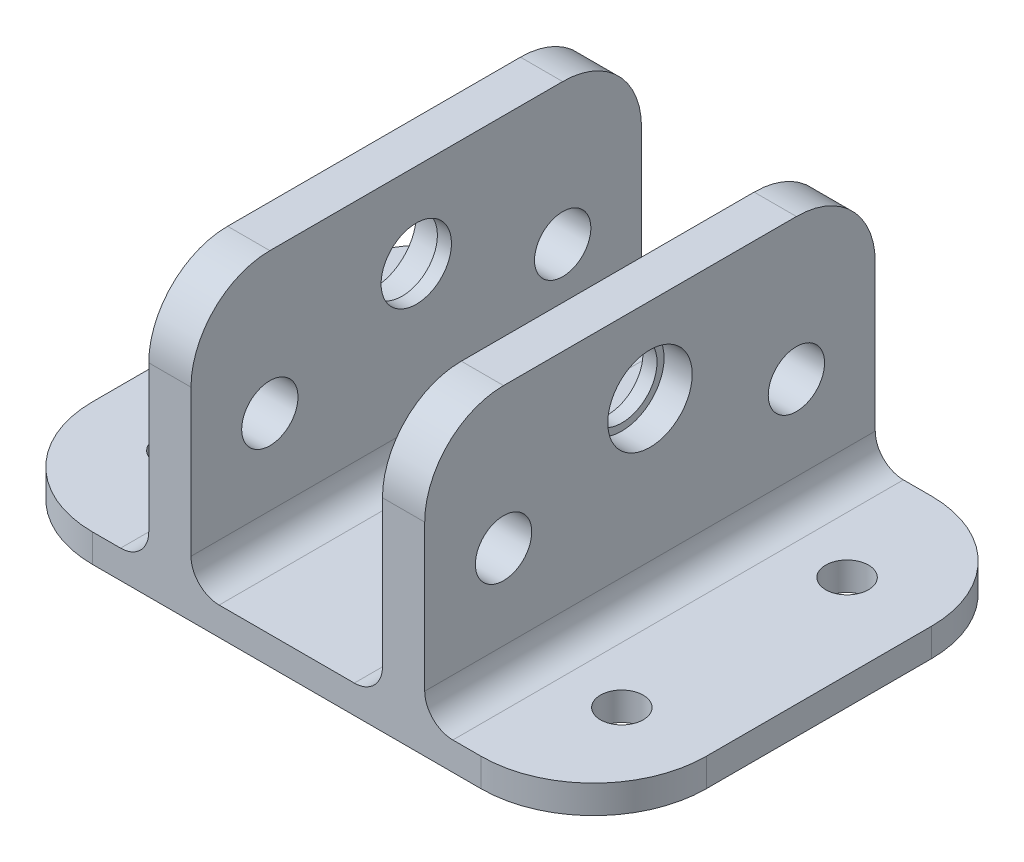
from build123d import *

# Parameters (mm, degrees)
BOSS_EXTRUDE2_DEPTH = 50.8
SKETCH4_R           = 3.175
SKETCH4_R_2         = 3.96875
CUT_EXTRUDE1_DEPTH  = 51.165
SKETCH5_R           = 2.413
CUT_EXTRUDE2_DEPTH  = 4.175
SKETCH4_3_R         = 4.7625
SKETCH4_3_R_2       = 3.96875
CUT_EXTRUDE3_DEPTH  = 3.175
SKETCH6_R           = 4.7625
SKETCH6_R_2         = 3.96875
CUT_EXTRUDE4_DEPTH  = 3.175
FILLET1_R           = 12.7
FILLET2_R           = 3.175
FILLET3_R           = 8.89


with BuildPart() as part:
    # Sketch3 → Boss-Extrude2 (new body)
    with BuildSketch(Plane.XY):
        Polygon((-34.6075, 0), (34.6075, 0), (34.6075, 3.175), (15.5575, 3.175), (15.5575, 31.75), (10.795, 31.75), (10.795, 3.175), (-10.795, 3.175), (-10.795, 31.75), (-15.5575, 31.75), (-15.5575, 3.175), (-34.6075, 3.175), align=None)
    extrude(amount=BOSS_EXTRUDE2_DEPTH)

    # Sketch4 → Cut-Extrude1 (cut, through all)
    with BuildSketch(Plane.ZY.offset(15.5575)):
        with Locations((8.89, 15.875)):
            Circle(SKETCH4_R)
        with Locations((41.91, 15.875)):
            Circle(SKETCH4_R)
        with Locations((25.4, 22.225)):
            Circle(SKETCH4_R_2)
    extrude(amount=-CUT_EXTRUDE1_DEPTH, mode=Mode.SUBTRACT)

    # Sketch5 → Cut-Extrude2 (cut, through all)
    with BuildSketch(Plane(origin=(0, 3.175, 0), x_dir=(1, 0, 0), z_dir=(0, 1, 0))):
        with Locations((-25.0825, -38.1)):
            Circle(SKETCH5_R)
        with Locations((-25.0825, -12.7)):
            Circle(SKETCH5_R)
        with Locations((25.0825, -12.7)):
            Circle(SKETCH5_R)
        with Locations((25.0825, -38.1)):
            Circle(SKETCH5_R)
    extrude(amount=-CUT_EXTRUDE2_DEPTH, mode=Mode.SUBTRACT)

    # Sketch4_3 → Cut-Extrude3 (cut)
    with BuildSketch(Plane.ZY.offset(15.5575)):
        with Locations((25.4, 22.225)):
            Circle(SKETCH4_3_R)
        with Locations((25.4, 22.225)):
            Circle(SKETCH4_3_R_2, mode=Mode.SUBTRACT)
    extrude(amount=-CUT_EXTRUDE3_DEPTH, mode=Mode.SUBTRACT)

    # Sketch6 → Cut-Extrude4 (cut)
    with BuildSketch(Plane(origin=(15.5575, 0, 0), x_dir=(0, 0, -1), z_dir=(1, 0, 0))):
        with Locations((-25.4, 22.225)):
            Circle(SKETCH6_R)
        with Locations((-25.4, 22.225)):
            Circle(SKETCH6_R_2, mode=Mode.SUBTRACT)
    extrude(amount=-CUT_EXTRUDE4_DEPTH, mode=Mode.SUBTRACT)

    # Fillet1
    fillet1_edges = [part.edges().sort_by_distance(p)[0] for p in [
        (34.6075, 1.5875, 50.8),
        (34.6075, 1.5875, 0),
        (-34.6075, 1.5875, 0),
        (-34.6075, 1.5875, 50.8),
    ]]
    fillet(fillet1_edges, radius=FILLET1_R)

    # Fillet2
    fillet2_edges = [part.edges().sort_by_distance(p)[0] for p in [
        (-15.5575, 3.175, 25.4),
        (-10.795, 3.175, 25.4),
        (10.795, 3.175, 25.4),
        (15.5575, 3.175, 25.4),
    ]]
    fillet(fillet2_edges, radius=FILLET2_R)

    # Fillet3
    fillet3_edges = [part.edges().sort_by_distance(p)[0] for p in [
        (-13.17625, 31.75, 0),
        (13.17625, 31.75, 0),
        (13.17625, 31.75, 50.8),
        (-13.17625, 31.75, 50.8),
    ]]
    fillet(fillet3_edges, radius=FILLET3_R)


solid = part.part
